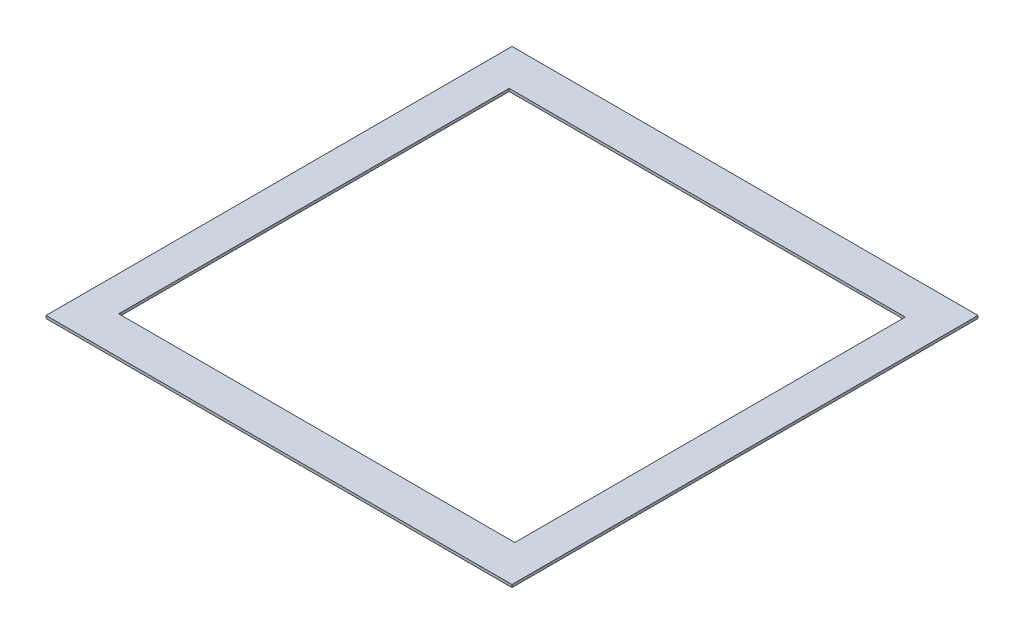
from build123d import *

# Parameters (mm, degrees)
SKETCH_3_W      = 2600
SKETCH_3_H      = 2600
SKETCH_3_W_2    = 2209.965574325
SKETCH_3_H_2    = 2178.657088224
EXTRUDE_2_DEPTH = 15


with BuildPart() as part:
    # 草图3 → 凸台-拉伸2 (new body)
    with BuildSketch(Plane(origin=(0, 0, 0), x_dir=(1, 0, 0), z_dir=(0, 1, 0))):
        with Locations((-21.487031147, 1021.241514165)):
            Rectangle(SKETCH_3_W, SKETCH_3_H)
        with Locations((-21.487031147, 1021.241514165)):
            Rectangle(SKETCH_3_W_2, SKETCH_3_H_2, mode=Mode.SUBTRACT)
    extrude(amount=EXTRUDE_2_DEPTH)


solid = part.part
